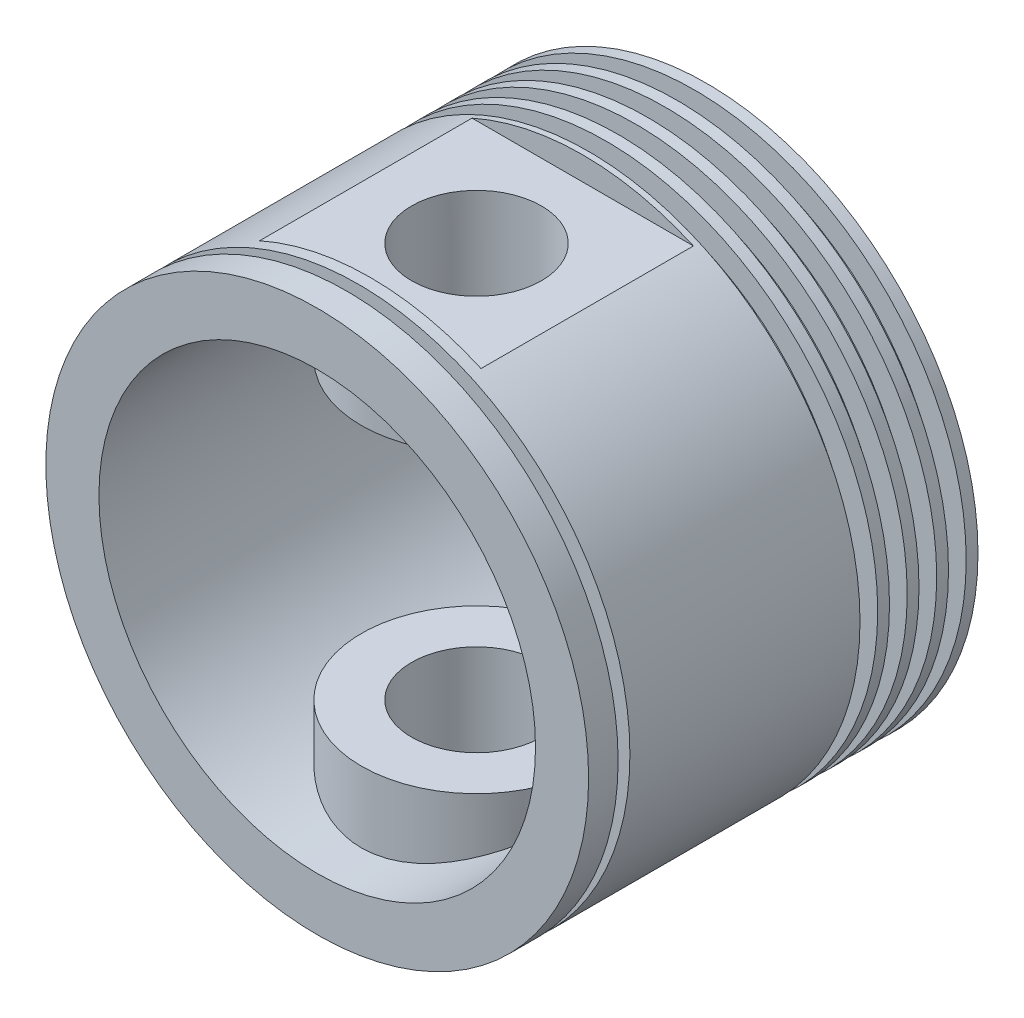
from build123d import *

# Parameters (mm, degrees)
BOSS_EXTRUDE1_REACH     = 96.152
SKETCH2_R               = 19.5
CUT_EXTRUDE2_DEPTH      = 78.069384359
CUT_EXTRUDE2_DEPTH_BACK = 78.069384359
SKETCH3_R               = 11
SKETCH7_W               = 36
SKETCH7_H               = 8
CUT_EXTRUDE4_DEPTH      = 78.069384479


with BuildPart() as part:
    # Sketch1 → Revolve1 (revolve)
    with BuildSketch(Plane(origin=(0, 0, 0), x_dir=(1, 0, 0), z_dir=(0, 1, 0))):
        Polygon((0, 41.324206049), (46, 41.324206049), (46, 39.324206049), (42, 39.324206049), (42, 36.324206049), (46, 36.324206049), (46, 34.324206049), (42, 34.324206049), (42, 31.324206049), (46, 31.324206049), (46, 29.324206049), (42, 29.324206049), (42, 26.324206049), (46, 26.324206049), (46, 24.324206049), (42, 24.324206049), (42, 21.324206049), (46, 21.324206049), (46, -17.675793951), (42, -17.675793951), (42, -19.675793951), (46, -19.675793951), (46, -24.675793951), (37, -24.675793951), (37, 22.858692986), (37, 37.324206049), (0, 37.324206049), align=None)
    revolve(axis=Axis((0, 0, 0), (0, 0, -1)))

    # Sketch2 → Boss-Extrude1 (add, up to next)
    with BuildSketch(Plane(origin=(0, 25, 0), x_dir=(1, 0, 0), z_dir=(0, 1, 0)), mode=Mode.PRIVATE) as boss_extrude1_sk1:
        with Locations((0, 2.324206049)):
            Circle(SKETCH2_R)
    boss_extrude1_tool1 = extrude(boss_extrude1_sk1.sketch, amount=BOSS_EXTRUDE1_REACH, mode=Mode.PRIVATE) - part.part
    boss_extrude1 = boss_extrude1_tool1.solids().sort_by_distance((0, 25, -2.324206))[0]
    add(boss_extrude1)

    # Mirror1: Boss-Extrude1 across plane
    add(boss_extrude1.mirror(Plane.ZX))

    # Sketch3 → Cut-Extrude2 (cut, two sides: drawn at the far end of the back side and taken through both)
    with BuildSketch(Plane(origin=(0, 0, 0), x_dir=(1, 0, 0), z_dir=(0, 1, 0)).offset(-CUT_EXTRUDE2_DEPTH_BACK)):
        with Locations((0, 2.324206049)):
            Circle(SKETCH3_R)
    extrude(amount=CUT_EXTRUDE2_DEPTH + CUT_EXTRUDE2_DEPTH_BACK, mode=Mode.SUBTRACT)

    # Sketch7 → Cut-Extrude4 (cut, symmetric)
    with BuildSketch(Plane(origin=(0, 0, 0), x_dir=(0, 0, -1), z_dir=(1, 0, 0))):
        with Locations((2.324206049, 46)):
            Rectangle(SKETCH7_W, SKETCH7_H)
    cut_extrude4 = extrude(amount=CUT_EXTRUDE4_DEPTH, both=True, mode=Mode.SUBTRACT)

    # Mirror2: Cut-Extrude4 across plane
    add(cut_extrude4.mirror(Plane.ZX), mode=Mode.SUBTRACT)


solid = part.part
